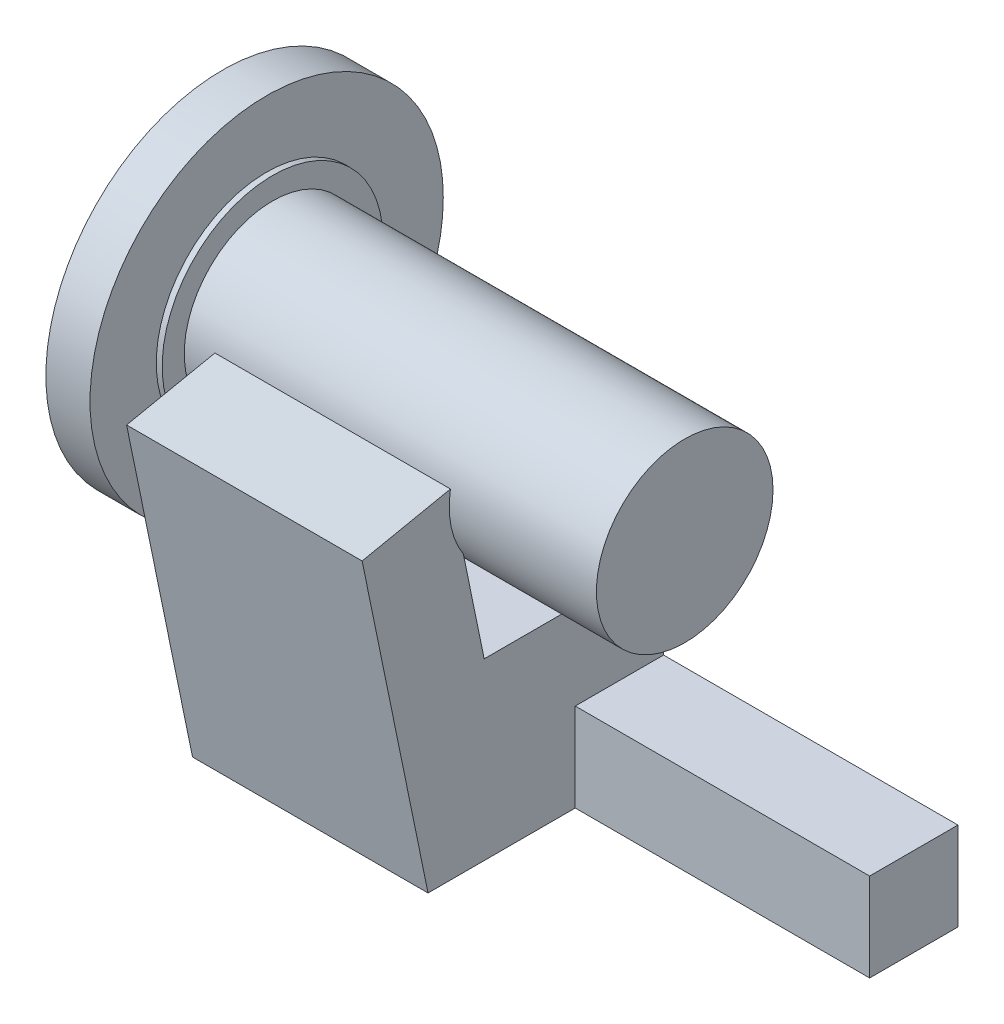
from build123d import *

# Parameters (mm, degrees)
SKETCH1_R           = 76.2
BOSS_EXTRUDE1_DEPTH = 19.05
SKETCH2_R           = 47.625
BOSS_EXTRUDE2_DEPTH = 2.54
SKETCH3_R           = 38.1
BOSS_EXTRUDE3_DEPTH = 177.8
SKETCH4_R           = 12.7
BOSS_EXTRUDE4_DEPTH = 31.75
BOSS_EXTRUDE5_DEPTH = 101.6
SKETCH8_W           = 38.1
SKETCH8_H           = 38.1
BOSS_EXTRUDE6_DEPTH = 127
SKETCH9_R           = 6.35
BOSS_EXTRUDE7_DEPTH = 2.54


with BuildPart() as part:
    # Sketch1 → Boss-Extrude1 (new body)
    with BuildSketch(Plane(origin=(0, 0, 0), x_dir=(0, 0, -1), z_dir=(1, 0, 0))):
        Circle(SKETCH1_R)
    extrude(amount=BOSS_EXTRUDE1_DEPTH)

    # Sketch2 → Boss-Extrude2 (add)
    with BuildSketch(Plane(origin=(19.05, 0, 0), x_dir=(0, 0, -1), z_dir=(1, 0, 0))):
        Circle(SKETCH2_R)
    extrude(amount=BOSS_EXTRUDE2_DEPTH)

    # Sketch3 → Boss-Extrude3 (add)
    with BuildSketch(Plane(origin=(21.59, 0, 0), x_dir=(0, 0, -1), z_dir=(1, 0, 0))):
        Circle(SKETCH3_R)
    extrude(amount=BOSS_EXTRUDE3_DEPTH)

    # Sketch4 → Boss-Extrude4 (add)
    with BuildSketch(Plane.ZY):
        Circle(SKETCH4_R)
    extrude(amount=BOSS_EXTRUDE4_DEPTH)

    # Sketch7 → Boss-Extrude5 (add)
    with BuildSketch(Plane(origin=(34.29, 0, 0), x_dir=(0, 0, -1), z_dir=(1, 0, 0))):
        with BuildLine():
            Line((-37.556058373, 6.415019833), (-75.656058373, -1.41999022))
            Line((-75.656058373, -1.41999022), (-47.219699668, -139.7))
            Line((-47.219699668, -139.7), (54.380300332, -139.7))
            Line((54.380300332, -139.7), (54.380300332, -109.367342085))
            Line((54.380300332, -109.367342085), (54.380300332, -87.28092842))
            ThreePointArc((54.380300332, -87.28092842), (47.900567457, -71.021979596), (31.729146835, -64.326794005))
            Line((31.729146835, -64.326794005), (-23.008477729, -64.326794005))
            Line((-23.008477729, -64.326794005), (-37.556058373, 6.415019833))
        make_face()
    extrude(amount=BOSS_EXTRUDE5_DEPTH)

    # Sketch8 → Boss-Extrude6 (add)
    with BuildSketch(Plane(origin=(135.89, 0, 0), x_dir=(0, 0, -1), z_dir=(1, 0, 0))):
        with Locations((35.330300332, -120.65)):
            Rectangle(SKETCH8_W, SKETCH8_H)
    extrude(amount=BOSS_EXTRUDE6_DEPTH)

    # Sketch9 → Boss-Extrude7 (add)
    with BuildSketch(Plane(origin=(0, -139.7, 0), x_dir=(-1, 0, 0), z_dir=(0, -1, 0))):
        with Locations((-40.64, 48.030300332)):
            Circle(SKETCH9_R)
    extrude(amount=BOSS_EXTRUDE7_DEPTH)


solid = part.part
